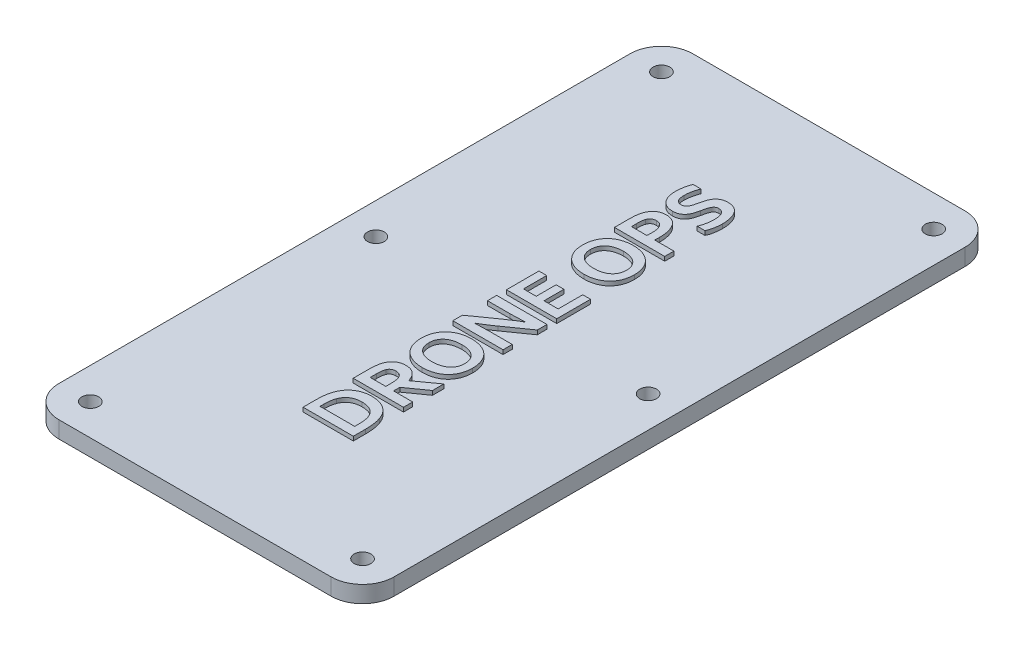
from build123d import *

# Parameters (mm, degrees)
CROQUIS1_W              = 80
CROQUIS1_H              = 151.368163876
CROQUIS1_R              = 2
SALIENTE_EXTRUIR1_DEPTH = 4
REDONDEO1_R             = 7.5
SALIENTE_EXTRUIR5_DEPTH = 1


with BuildPart() as part:
    # Croquis1 → Saliente-Extruir1 (new body)
    with BuildSketch(Plane(origin=(0, 0, 0), x_dir=(1, 0, 0), z_dir=(0, 1, 0))):
        with Locations((0, -7.276430304)):
            Rectangle(CROQUIS1_W, CROQUIS1_H)
        with Locations((32.5, 60.907651634)):
            Circle(CROQUIS1_R, mode=Mode.SUBTRACT)
        with Locations((-32.5, 60.907651634)):
            Circle(CROQUIS1_R, mode=Mode.SUBTRACT)
        with Locations((-32.5, -75.460512242)):
            Circle(CROQUIS1_R, mode=Mode.SUBTRACT)
        with Locations((32.5, -75.460512242)):
            Circle(CROQUIS1_R, mode=Mode.SUBTRACT)
        with Locations((-32.5, -7.276430304)):
            Circle(CROQUIS1_R, mode=Mode.SUBTRACT)
        with Locations((32.5, -7.276430304)):
            Circle(CROQUIS1_R, mode=Mode.SUBTRACT)
    extrude(amount=SALIENTE_EXTRUIR1_DEPTH)

    # Redondeo1
    redondeo1_edges = [part.edges().sort_by_distance(p)[0] for p in [
        (40, 2, 82.960512242),
        (-40, 2, 82.960512242),
        (-40, 2, -68.407651634),
        (40, 2, -68.407651634),
    ]]
    fillet(redondeo1_edges, radius=REDONDEO1_R)

    # Croquis3 → Saliente-Extruir5 (add)
    with BuildSketch(Plane(origin=(0, 4, 0), x_dir=(1, 0, 0), z_dir=(0, 1, 0))):
        with BuildLine():
            Line((7.049424333, -52.217275374), (-4.950575667, -52.217275374))
            Line((-4.950575667, -52.217275374), (-4.950575667, -48.995444388))
            add(Edge.make_bspline(
                [(-4.950575667, -48.995444388), (-4.948523154, -48.851949224), (-4.944378847, -48.562212774), (-4.92730262, -48.126087874), (-4.891577532, -47.693030468), (-4.848814952, -47.268061007), (-4.786358549, -46.857168032), (-4.716858455, -46.461269082), (-4.635295464, -46.086447791), (-4.563009273, -45.848910576), (-4.528040456, -45.734000726)],
                knots=[0, 0, 0, 0, 0.000430531, 0.000869301, 0.001309023, 0.001733937, 0.002150362, 0.002555454, 0.002939858, 0.00330007, 0.00330007, 0.00330007, 0.00330007], degree=3))
            add(Edge.make_bspline(
                [(-4.528040456, -45.734000726), (-4.474936266, -45.575552411), (-4.370571569, -45.264156821), (-4.176252716, -44.81949364), (-3.956494486, -44.402811884), (-3.711042013, -44.013622551), (-3.439225332, -43.653710927), (-3.141517627, -43.325944824), (-2.824552879, -43.024047985), (-2.479072213, -42.758648153), (-2.114049229, -42.518500696), (-1.725671208, -42.31424883), (-1.317946247, -42.138020243), (-0.89047826, -41.993357102), (-0.442788873, -41.879653782), (0.023331231, -41.798682343), (0.507738343, -41.746390407), (0.837139041, -41.741093735), (1.004529966, -41.738402135)],
                knots=[0, 0, 0, 0, 0.000501135, 0.000984871, 0.001453857, 0.001913227, 0.002363761, 0.002805027, 0.003240318, 0.003675064, 0.004110155, 0.004549623, 0.004989663, 0.005441464, 0.005901986, 0.00637393, 0.006859802, 0.007361813, 0.007361813, 0.007361813, 0.007361813], degree=3))
            add(Edge.make_bspline(
                [(1.004529966, -41.738402135), (1.163964766, -41.740610801), (1.478133149, -41.744963008), (1.941071201, -41.789184471), (2.388379819, -41.856893054), (2.819665016, -41.952527408), (3.235822859, -42.072044112), (3.631499436, -42.226351035), (4.009669927, -42.406760382), (4.369283718, -42.615769915), (4.710769506, -42.852572732), (5.028952578, -43.122279989), (5.328389333, -43.418130797), (5.605874188, -43.744642687), (5.86438984, -44.099861882), (6.095282593, -44.488521501), (6.303300473, -44.907802226), (6.417902524, -45.20309195), (6.476360952, -45.353719036)],
                knots=[0, 0, 0, 0, 0.000478175, 0.000942251, 0.001393804, 0.001834636, 0.002266678, 0.002691387, 0.003107167, 0.003522519, 0.003937905, 0.004352113, 0.004772273, 0.005199356, 0.005636214, 0.006088663, 0.006553991, 0.007038506, 0.007038506, 0.007038506, 0.007038506], degree=3))
            add(Edge.make_bspline(
                [(6.476360952, -45.353719036), (6.522989524, -45.48609498), (6.618730213, -45.757897513), (6.731996716, -46.185622881), (6.830484008, -46.638459376), (6.908312721, -47.118209271), (6.972500345, -47.625460889), (7.015498562, -48.163892985), (7.046669017, -48.732754074), (7.048491179, -49.123038972), (7.049424333, -49.322909177)],
                knots=[0, 0, 0, 0, 0.000420898, 0.000864214, 0.001326249, 0.001810763, 0.002321751, 0.002859719, 0.003430881, 0.004030405, 0.004030405, 0.004030405, 0.004030405], degree=3))
            Line((7.049424333, -49.322909177), (7.049424333, -52.217275374))
        make_face()
        with BuildLine():
            add(Edge.make_bspline(
                [(5.190269403, -49.106359881), (5.188764848, -48.948763947), (5.185837977, -48.642186404), (5.162748377, -48.195356713), (5.120339661, -47.775100407), (5.062758785, -47.3810956), (4.98999848, -47.013986169), (4.89910393, -46.673908578), (4.796609643, -46.358002573), (4.707868798, -46.162002275), (4.664741234, -46.066747205)],
                knots=[0, 0, 0, 0, 0.000472778, 0.000919713, 0.001341728, 0.00173948, 0.002113931, 0.002463681, 0.00279522, 0.003108692, 0.003108692, 0.003108692, 0.003108692], degree=3))
            add(Edge.make_bspline(
                [(4.664741234, -46.066747205), (4.624786689, -45.98760084), (4.545738823, -45.831014118), (4.403985814, -45.613028146), (4.252366127, -45.406734975), (4.087688843, -45.21557053), (3.90838738, -45.038969819), (3.71601359, -44.877950214), (3.508482324, -44.732767363), (3.289502122, -44.599805892), (3.054859143, -44.483916807), (2.807103884, -44.379289095), (2.540978352, -44.296980777), (2.261363664, -44.22366166), (1.964187815, -44.173239263), (1.652445644, -44.132809661), (1.324441651, -44.108966394), (1.100518365, -44.106076627), (0.986044051, -44.104599318)],
                knots=[0, 0, 0, 0, 0.000265796, 0.000525862, 0.00077886, 0.001033506, 0.001281872, 0.0015331, 0.001785145, 0.002041034, 0.002300859, 0.002569616, 0.002846892, 0.00313576, 0.003436214, 0.003750341, 0.004078667, 0.004422068, 0.004422068, 0.004422068, 0.004422068], degree=3))
            add(Edge.make_bspline(
                [(0.986044051, -44.104599318), (0.867162639, -44.106846616), (0.635198208, -44.111231602), (0.295141901, -44.139048642), (-0.026570389, -44.192879607), (-0.331274474, -44.263300309), (-0.618758465, -44.354218056), (-0.890478689, -44.461233906), (-1.145643673, -44.588856556), (-1.383618699, -44.734564211), (-1.606026287, -44.896239777), (-1.813873041, -45.072660057), (-2.000965376, -45.270724899), (-2.176152355, -45.481508175), (-2.334291533, -45.709084022), (-2.47645287, -45.950831838), (-2.60815122, -46.204497026), (-2.680011729, -46.38299776), (-2.716420738, -46.473437346)],
                knots=[0, 0, 0, 0, 0.000356671, 0.000695945, 0.001022428, 0.001334384, 0.001633394, 0.001926159, 0.002209604, 0.002488148, 0.0027623, 0.003033845, 0.00330467, 0.003578555, 0.003855479, 0.004134923, 0.004419559, 0.004711882, 0.004711882, 0.004711882, 0.004711882], degree=3))
            add(Edge.make_bspline(
                [(-2.716420738, -46.473437346), (-2.777152631, -46.654476562), (-2.903247191, -47.030359139), (-2.991598855, -47.529225794), (-3.045023243, -47.955889289), (-3.068680879, -48.301560594), (-3.089599031, -48.665968616), (-3.090803808, -48.915302922), (-3.091420738, -49.0429796)],
                knots=[0, 0, 0, 0, 0.000572186, 0.001188002, 0.001515232, 0.00186219, 0.002227095, 0.002610054, 0.002610054, 0.002610054, 0.002610054], degree=3))
            Line((-3.091420738, -49.0429796), (-3.091420738, -50.020092276))
            Line((-3.091420738, -50.020092276), (5.190269403, -50.020092276))
            Line((5.190269403, -50.020092276), (5.190269403, -49.106359881))
        make_face(mode=Mode.SUBTRACT)
        with BuildLine():
            add(Edge.make_bspline(
                [(-1.30620947, -31.284881008), (-1.202270164, -31.286910904), (-0.998293549, -31.29089449), (-0.697724688, -31.322270045), (-0.409787893, -31.379594677), (-0.131916212, -31.450610322), (0.131284482, -31.550931645), (0.384108127, -31.669100989), (0.623075788, -31.812809335), (0.852970533, -31.97366962), (1.066166658, -32.160238938), (1.269701454, -32.366193073), (1.45246747, -32.600727817), (1.626896867, -32.854760496), (1.780145643, -33.135994731), (1.924889828, -33.438182233), (2.050175123, -33.765730339), (2.121928774, -33.993992818), (2.158579262, -34.110585233)],
                knots=[0, 0, 0, 0, 0.000311799, 0.000611892, 0.000905038, 0.001192016, 0.001471123, 0.001748726, 0.002028169, 0.002306612, 0.002589331, 0.002876928, 0.00317388, 0.003480047, 0.003800417, 0.004133541, 0.004484684, 0.004851305, 0.004851305, 0.004851305, 0.004851305], degree=3))
            Line((2.158579262, -34.110585233), (2.192910248, -34.110585233))
            Line((2.192910248, -34.110585233), (7.049424333, -30.60882467))
            Line((7.049424333, -30.60882467), (7.049424333, -33.313050022))
            Line((7.049424333, -33.313050022), (2.486044051, -36.550726078))
            Line((2.486044051, -36.550726078), (2.486044051, -38.045444388))
            Line((2.486044051, -38.045444388), (7.049424333, -38.045444388))
            Line((7.049424333, -38.045444388), (7.049424333, -40.242627487))
            Line((7.049424333, -40.242627487), (-4.950575667, -40.242627487))
            Line((-4.950575667, -40.242627487), (-4.950575667, -36.561289459))
            add(Edge.make_bspline(
                [(-4.950575667, -36.561289459), (-4.950088257, -36.41160795), (-4.949127249, -36.116486736), (-4.925845242, -35.682436218), (-4.895679475, -35.263927428), (-4.850571483, -34.864044611), (-4.795092809, -34.485357291), (-4.719432395, -34.134410245), (-4.6379323, -33.810534951), (-4.567308899, -33.608392354), (-4.533322146, -33.511113402)],
                knots=[0, 0, 0, 0, 0.000448975, 0.000885226, 0.001303681, 0.001707592, 0.002092287, 0.002451218, 0.0027843, 0.00309329, 0.00309329, 0.00309329, 0.00309329], degree=3))
            add(Edge.make_bspline(
                [(-4.533322146, -33.511113402), (-4.498218957, -33.424422699), (-4.429273236, -33.254154609), (-4.310036886, -33.00885297), (-4.175197982, -32.780324941), (-4.029943156, -32.56574785), (-3.873883566, -32.366251361), (-3.704348366, -32.18333525), (-3.520828226, -32.016301656), (-3.325633995, -31.863893891), (-3.119709944, -31.723475682), (-2.89616069, -31.609792284), (-2.663301592, -31.507513654), (-2.416507032, -31.426156142), (-2.15690776, -31.362411372), (-1.884741214, -31.319380578), (-1.600088862, -31.287550101), (-1.40577702, -31.285785308), (-1.30620947, -31.284881008)],
                knots=[0, 0, 0, 0, 0.000280539, 0.000551004, 0.000817323, 0.001075884, 0.001327887, 0.001576421, 0.001823167, 0.002071463, 0.002319027, 0.002569448, 0.002822584, 0.003081468, 0.003347918, 0.003623605, 0.003907665, 0.004206186, 0.004206186, 0.004206186, 0.004206186], degree=3))
        make_face()
        with BuildLine():
            add(Edge.make_bspline(
                [(0.626889121, -36.9679796), (0.625321319, -36.847388761), (0.622322461, -36.616725194), (0.614956658, -36.284414485), (0.588480869, -35.981801038), (0.562248024, -35.704673392), (0.520576232, -35.453225338), (0.477364069, -35.221694675), (0.423158138, -35.011442966), (0.376881141, -34.880553617), (0.354882079, -34.818331712)],
                knots=[0, 0, 0, 0, 0.000361834, 0.000692109, 0.000996735, 0.001272915, 0.001526903, 0.001761002, 0.001979427, 0.002177349, 0.002177349, 0.002177349, 0.002177349], degree=3))
            add(Edge.make_bspline(
                [(0.354882079, -34.818331712), (0.312087135, -34.715637471), (0.23025709, -34.519271416), (0.066714585, -34.261732452), (-0.121474746, -34.054245072), (-0.333942007, -33.898760418), (-0.566350691, -33.787596362), (-0.813426851, -33.708469334), (-1.077184465, -33.659626313), (-1.258461918, -33.653969241), (-1.351103836, -33.651078191)],
                knots=[0, 0, 0, 0, 0.000333301, 0.00063732, 0.000910185, 0.001169001, 0.001421751, 0.001679811, 0.001945541, 0.002223282, 0.002223282, 0.002223282, 0.002223282], degree=3))
            add(Edge.make_bspline(
                [(-1.351103836, -33.651078191), (-1.430468487, -33.65368767), (-1.584812945, -33.658762455), (-1.810363012, -33.696273902), (-2.021128387, -33.760013627), (-2.220281361, -33.845661208), (-2.399320431, -33.967248509), (-2.561764085, -34.120867486), (-2.701258899, -34.312375989), (-2.773974021, -34.457990892), (-2.81149116, -34.533120445)],
                knots=[0, 0, 0, 0, 0.000238043, 0.000462933, 0.000683503, 0.000897477, 0.001110618, 0.001329171, 0.001565272, 0.001816929, 0.001816929, 0.001816929, 0.001816929], degree=3))
            add(Edge.make_bspline(
                [(-2.81149116, -34.533120445), (-2.834303543, -34.588273449), (-2.881811987, -34.703133583), (-2.939841821, -34.889345541), (-2.985979535, -35.096281357), (-3.02646471, -35.324332343), (-3.054076271, -35.576691892), (-3.075100414, -35.855011863), (-3.08808611, -36.160642618), (-3.090279279, -36.373776886), (-3.091420738, -36.484704952)],
                knots=[0, 0, 0, 0, 0.000178994, 0.000372768, 0.000584168, 0.000814709, 0.001067265, 0.001345358, 0.00165198, 0.001984769, 0.001984769, 0.001984769, 0.001984769], degree=3))
            Line((-3.091420738, -36.484704952), (-3.091420738, -38.045444388))
            Line((-3.091420738, -38.045444388), (0.626889121, -38.045444388))
            Line((0.626889121, -38.045444388), (0.626889121, -36.9679796))
        make_face(mode=Mode.SUBTRACT)
        with BuildLine():
            add(Edge.make_bspline(
                [(1.049424333, -17.958120445), (1.271465002, -17.962345895), (1.708020953, -17.970653586), (2.347706217, -18.046070388), (2.959357652, -18.169655763), (3.539673036, -18.344173074), (4.087804933, -18.562183321), (4.598928225, -18.827589361), (5.070347894, -19.139495353), (5.501075201, -19.497918992), (5.886966265, -19.900925871), (6.232053229, -20.345557317), (6.526563104, -20.835755896), (6.776526134, -21.367052712), (6.97439799, -21.938745782), (7.116940499, -22.55007293), (7.202005574, -23.199560151), (7.212873849, -23.64536228), (7.218438417, -23.873613402)],
                knots=[0, 0, 0, 0, 0.000665917, 0.001309265, 0.001929212, 0.002535779, 0.003124741, 0.003696433, 0.004260413, 0.004817306, 0.005373892, 0.005931166, 0.006502279, 0.007085876, 0.007689706, 0.008313617, 0.008966119, 0.009650715, 0.009650715, 0.009650715, 0.009650715], degree=3))
            add(Edge.make_bspline(
                [(7.218438417, -23.873613402), (7.212875077, -24.101865313), (7.202009199, -24.547668982), (7.116927035, -25.197145232), (6.974445439, -25.808511483), (6.776357472, -26.380065819), (6.527484277, -26.911174242), (6.230337831, -27.39960334), (5.887998527, -27.8461972), (5.500935034, -28.249218054), (5.070360996, -28.607690277), (4.59901979, -28.919898424), (4.087121754, -29.184165061), (3.540823172, -29.407223001), (2.958746645, -29.576480612), (2.347808391, -29.701476033), (1.707993954, -29.77648876), (1.2714559, -29.784852436), (1.049424333, -29.78910636)],
                knots=[0, 0, 0, 0, 0.000684595, 0.001337098, 0.001961008, 0.002564839, 0.003148436, 0.003717291, 0.004276658, 0.004833244, 0.005390137, 0.005954116, 0.006525809, 0.007115759, 0.007721572, 0.008341519, 0.008984867, 0.009650784, 0.009650784, 0.009650784, 0.009650784], degree=3))
            add(Edge.make_bspline(
                [(1.049424333, -29.78910636), (0.827383981, -29.78491661), (0.391703346, -29.776695613), (-0.247981767, -29.700901405), (-0.859103207, -29.576904173), (-1.44196563, -29.407176094), (-1.988275107, -29.184176942), (-2.500171507, -28.919895776), (-2.971508901, -28.607689333), (-3.402099532, -28.249224337), (-3.789100495, -27.846172945), (-4.131675807, -27.399695231), (-4.428113451, -26.910498783), (-4.680609265, -26.380751937), (-4.878830931, -25.808799077), (-5.017214361, -25.196755422), (-5.103400284, -24.547720611), (-5.114107597, -24.101882796), (-5.119589752, -23.873613402)],
                knots=[0, 0, 0, 0, 0.000665917, 0.001306642, 0.001929176, 0.00253499, 0.003124939, 0.003696632, 0.004260612, 0.004817504, 0.00537409, 0.005933457, 0.006502313, 0.007087038, 0.007690868, 0.00831418, 0.008966683, 0.009651278, 0.009651278, 0.009651278, 0.009651278], degree=3))
            add(Edge.make_bspline(
                [(-5.119589752, -23.873613402), (-5.114106372, -23.645344796), (-5.103396666, -23.199508517), (-5.017227791, -22.550462757), (-4.878783631, -21.938458107), (-4.680777716, -21.366366676), (-4.427187787, -20.836433757), (-4.133390607, -20.345465741), (-3.788068348, -19.900950066), (-3.40223969, -19.497912713), (-2.971495798, -19.139496305), (-2.500079953, -18.827591974), (-1.988958242, -18.562171582), (-1.440815674, -18.344219397), (-0.859716018, -18.169226442), (-0.247879888, -18.046644081), (0.391676387, -17.970446863), (0.82737488, -17.962281726), (1.049424333, -17.958120445)],
                knots=[0, 0, 0, 0, 0.000684595, 0.001337098, 0.00196041, 0.00256424, 0.003148966, 0.003720078, 0.004277353, 0.004833939, 0.005390832, 0.005954811, 0.006526504, 0.007115466, 0.007722033, 0.008344567, 0.008985292, 0.009651209, 0.009651209, 0.009651209, 0.009651209], degree=3))
        make_face()
        with BuildLine():
            add(Edge.make_bspline(
                [(1.049424333, -20.324317628), (0.87500092, -20.326956793), (0.536824062, -20.332073678), (0.045831608, -20.382985759), (-0.41172137, -20.466547432), (-0.835855597, -20.582517414), (-1.225541833, -20.727818868), (-1.581613852, -20.899259422), (-1.903980819, -21.098342715), (-2.191696037, -21.323317521), (-2.448659521, -21.568895854), (-2.665398048, -21.841759928), (-2.852983749, -22.133508227), (-3.002617835, -22.449095073), (-3.11940724, -22.782958498), (-3.199656857, -23.132944479), (-3.252690578, -23.497873107), (-3.257818225, -23.746659619), (-3.260434822, -23.873613402)],
                knots=[0, 0, 0, 0, 0.000523127, 0.001014254, 0.00147887, 0.001917091, 0.002331577, 0.002724886, 0.003100833, 0.003465863, 0.003818838, 0.004164456, 0.00450878, 0.004857231, 0.005209683, 0.005567759, 0.005933017, 0.006313629, 0.006313629, 0.006313629, 0.006313629], degree=3))
            add(Edge.make_bspline(
                [(-3.260434822, -23.873613402), (-3.257818146, -24.0005671), (-3.252690343, -24.249353446), (-3.199657743, -24.61428328), (-3.119404005, -24.964264825), (-3.002629655, -25.29814445), (-2.852940384, -25.613671915), (-2.665558077, -25.905639072), (-2.447669859, -26.178160156), (-2.193519408, -26.426891312), (-1.90291108, -26.64841823), (-1.581787821, -26.84818127), (-1.225491579, -27.019346152), (-0.835870208, -27.164727355), (-0.411717104, -27.280674128), (0.04583037, -27.364242567), (0.536824402, -27.415152708), (0.875001036, -27.42026987), (1.049424333, -27.422909177)],
                knots=[0, 0, 0, 0, 0.000380612, 0.00074587, 0.001103946, 0.001456397, 0.001804849, 0.002149173, 0.002494791, 0.002849609, 0.00321302, 0.003588967, 0.003982276, 0.004396762, 0.004834984, 0.0052996, 0.005790726, 0.006313853, 0.006313853, 0.006313853, 0.006313853], degree=3))
            add(Edge.make_bspline(
                [(1.049424333, -27.422909177), (1.223849823, -27.420277818), (1.562030712, -27.415176067), (2.052994865, -27.364157702), (2.509810752, -27.281118642), (2.932811889, -27.164212459), (3.321730295, -27.019424902), (3.677934353, -26.848075953), (3.998729722, -26.649112684), (4.287420445, -26.42699933), (4.538425043, -26.176447272), (4.75944025, -25.906635579), (4.946491749, -25.613588588), (5.095752928, -25.297673683), (5.215562125, -24.964436838), (5.299167638, -24.61462576), (5.351356485, -24.249316488), (5.35660514, -24.000554613), (5.359283488, -23.873613402)],
                knots=[0, 0, 0, 0, 0.000523127, 0.001014254, 0.00147887, 0.001914545, 0.002329032, 0.00272234, 0.003098288, 0.003459611, 0.003812547, 0.004159825, 0.004504149, 0.004852601, 0.005205932, 0.00556462, 0.005929879, 0.00631049, 0.00631049, 0.00631049, 0.00631049], degree=3))
            add(Edge.make_bspline(
                [(5.359283488, -23.873613402), (5.35660522, -23.746672107), (5.35135672, -23.497910065), (5.299166746, -23.132601995), (5.215565387, -22.78278649), (5.095741013, -22.449565823), (4.946535338, -22.133591747), (4.759279055, -21.840763075), (4.539427422, -21.570607268), (4.285597138, -21.323189395), (3.999806378, -21.097651654), (3.677758859, -20.899364569), (3.321780999, -20.727740156), (2.932797245, -20.583032179), (2.509815045, -20.466102934), (2.052993616, -20.383070623), (1.562031055, -20.33205032), (1.22384994, -20.326948845), (1.049424333, -20.324317628)],
                knots=[0, 0, 0, 0, 0.000380612, 0.00074587, 0.001104559, 0.00145789, 0.001806341, 0.002150665, 0.002497944, 0.002849027, 0.003211978, 0.003587925, 0.003981234, 0.00439572, 0.004831396, 0.005296012, 0.005787138, 0.006310265, 0.006310265, 0.006310265, 0.006310265], degree=3))
        make_face(mode=Mode.SUBTRACT)
        with BuildLine():
            add(Edge.make_bspline(
                [(0.629529966, -10.222028895), (0.780964497, -10.117316852), (1.078202156, -9.911786696), (1.515565324, -9.608351209), (1.944694797, -9.327219892), (2.359224613, -9.057733701), (2.759037914, -8.800722087), (3.149297253, -8.563081533), (3.524946059, -8.339026874), (3.772815283, -8.197037397), (3.893614473, -8.127838755)],
                knots=[0, 0, 0, 0, 0.000552341, 0.001084142, 0.001596853, 0.002091284, 0.002567465, 0.003022649, 0.003461966, 0.003879604, 0.003879604, 0.003879604, 0.003879604], degree=3))
            Line((3.893614473, -8.127838755), (3.893614473, -8.075021853))
            add(Edge.make_bspline(
                [(3.893614473, -8.075021853), (3.705237021, -8.083010445), (3.341699485, -8.098427115), (2.816172845, -8.11964457), (2.330248413, -8.137862504), (1.884003732, -8.154825628), (1.477256451, -8.16463032), (1.111062316, -8.17274632), (0.78447436, -8.178345879), (0.580235809, -8.179917364), (0.484283488, -8.180655656)],
                knots=[0, 0, 0, 0, 0.00056564, 0.001091593, 0.00157786, 0.002024444, 0.002431271, 0.002798434, 0.003123301, 0.003411165, 0.003411165, 0.003411165, 0.003411165], degree=3))
            Line((0.484283488, -8.180655656), (-4.950575667, -8.180655656))
            Line((-4.950575667, -8.180655656), (-4.950575667, -5.983472557))
            Line((-4.950575667, -5.983472557), (7.049424333, -5.983472557))
            Line((7.049424333, -5.983472557), (7.049424333, -8.283648614))
            Line((7.049424333, -8.283648614), (1.524776445, -12.186817628))
            add(Edge.make_bspline(
                [(1.524776445, -12.186817628), (1.277547255, -12.361707875), (0.768790756, -12.721602876), (-0.035770077, -13.247846362), (-0.897157935, -13.784542801), (-1.495567469, -14.137058479), (-1.802688343, -14.3179796)],
                knots=[0, 0, 0, 0, 0.000908439, 0.001869417, 0.002883601, 0.003952908, 0.003952908, 0.003952908, 0.003952908], degree=3))
            Line((-1.802688343, -14.3179796), (-1.802688343, -14.373437346))
            add(Edge.make_bspline(
                [(-1.802688343, -14.373437346), (-1.624006364, -14.364305768), (-1.277261275, -14.346585291), (-0.772779926, -14.326217518), (-0.299191487, -14.307707785), (0.143539128, -14.290882472), (0.555569315, -14.281093658), (0.935848215, -14.272940261), (1.285325643, -14.267412066), (1.508049536, -14.265890414), (1.614565178, -14.265162698)],
                knots=[0, 0, 0, 0, 0.000536742, 0.001041585, 0.001514658, 0.001958603, 0.00237071, 0.002751074, 0.003099706, 0.003419259, 0.003419259, 0.003419259, 0.003419259], degree=3))
            Line((1.614565178, -14.265162698), (7.049424333, -14.265162698))
            Line((7.049424333, -14.265162698), (7.049424333, -16.462345797))
            Line((7.049424333, -16.462345797), (-4.950575667, -16.462345797))
            Line((-4.950575667, -16.462345797), (-4.950575667, -14.16216974))
            Line((-4.950575667, -14.16216974), (0.629529966, -10.222028895))
        make_face()
        Polygon((5.190269403, -1.445444388), (5.190269403, 4.419872513), (7.049424333, 4.419872513), (7.049424333, -3.642627487), (-4.950575667, -3.642627487), (-4.950575667, 4.097689414), (-3.091420738, 4.097689414), (-3.091420738, -1.445444388), (-0.049167217, -1.445444388), (-0.049167217, 3.313358429), (1.809987713, 3.313358429), (1.809987713, -1.445444388), align=None)
        with BuildLine():
            add(Edge.make_bspline(
                [(1.049424333, 20.644696457), (1.271465002, 20.640471007), (1.708020953, 20.632163315), (2.347706217, 20.556746514), (2.959357652, 20.433161138), (3.539673036, 20.258643828), (4.087804933, 20.04063358), (4.598928225, 19.77522754), (5.070347894, 19.463321548), (5.501075201, 19.104897909), (5.886966265, 18.70189103), (6.232053229, 18.257259584), (6.526563104, 17.767061006), (6.776526134, 17.23576419), (6.97439799, 16.664071119), (7.116940499, 16.052743971), (7.202005574, 15.403256751), (7.212873849, 14.957454621), (7.218438417, 14.729203499)],
                knots=[0, 0, 0, 0, 0.000665917, 0.001309265, 0.001929212, 0.002535779, 0.003124741, 0.003696433, 0.004260413, 0.004817306, 0.005373892, 0.005931166, 0.006502279, 0.007085876, 0.007689706, 0.008313617, 0.008966119, 0.009650715, 0.009650715, 0.009650715, 0.009650715], degree=3))
            add(Edge.make_bspline(
                [(7.218438417, 14.729203499), (7.212875077, 14.500951589), (7.202009199, 14.05514792), (7.116927035, 13.40567167), (6.974445439, 12.794305419), (6.776357472, 12.222751082), (6.527484277, 11.691642659), (6.230337831, 11.203213562), (5.887998527, 10.756619701), (5.500935034, 10.353598848), (5.070360996, 9.995126624), (4.59901979, 9.682918478), (4.087121754, 9.41865184), (3.540823172, 9.195593901), (2.958746645, 9.026336289), (2.347808391, 8.901340868), (1.707993954, 8.826328141), (1.2714559, 8.817964466), (1.049424333, 8.813710541)],
                knots=[0, 0, 0, 0, 0.000684595, 0.001337098, 0.001961008, 0.002564839, 0.003148436, 0.003717291, 0.004276658, 0.004833244, 0.005390137, 0.005954116, 0.006525809, 0.007115759, 0.007721572, 0.008341519, 0.008984867, 0.009650784, 0.009650784, 0.009650784, 0.009650784], degree=3))
            add(Edge.make_bspline(
                [(1.049424333, 8.813710541), (0.827383981, 8.817900292), (0.391703346, 8.826121289), (-0.247981767, 8.901915496), (-0.859103207, 9.025912728), (-1.44196563, 9.195640807), (-1.988275107, 9.41863996), (-2.500171507, 9.682921125), (-2.971508901, 9.995127569), (-3.402099532, 10.353592564), (-3.789100495, 10.756643957), (-4.131675807, 11.20312167), (-4.428113451, 11.692318118), (-4.680609265, 12.222064964), (-4.878830931, 12.794017824), (-5.017214361, 13.406061479), (-5.103400284, 14.05509629), (-5.114107597, 14.500934106), (-5.119589752, 14.729203499)],
                knots=[0, 0, 0, 0, 0.000665917, 0.001306642, 0.001929176, 0.00253499, 0.003124939, 0.003696632, 0.004260612, 0.004817504, 0.00537409, 0.005933457, 0.006502313, 0.007087038, 0.007690868, 0.00831418, 0.008966683, 0.009651278, 0.009651278, 0.009651278, 0.009651278], degree=3))
            add(Edge.make_bspline(
                [(-5.119589752, 14.729203499), (-5.114106372, 14.957472105), (-5.103396666, 15.403308384), (-5.017227791, 16.052354145), (-4.878783631, 16.664358794), (-4.680777716, 17.236450225), (-4.427187787, 17.766383145), (-4.133390607, 18.257351161), (-3.788068348, 18.701866836), (-3.40223969, 19.104904189), (-2.971495798, 19.463320597), (-2.500079953, 19.775224927), (-1.988958242, 20.040645319), (-1.440815674, 20.258597505), (-0.859716018, 20.43359046), (-0.247879888, 20.556172821), (0.391676387, 20.632370038), (0.82737488, 20.640535175), (1.049424333, 20.644696457)],
                knots=[0, 0, 0, 0, 0.000684595, 0.001337098, 0.00196041, 0.00256424, 0.003148966, 0.003720078, 0.004277353, 0.004833939, 0.005390832, 0.005954811, 0.006526504, 0.007115466, 0.007722033, 0.008344567, 0.008985292, 0.009651209, 0.009651209, 0.009651209, 0.009651209], degree=3))
        make_face()
        with BuildLine():
            add(Edge.make_bspline(
                [(1.049424333, 18.278499274), (0.87500092, 18.275860109), (0.536824062, 18.270743224), (0.045831608, 18.219831143), (-0.41172137, 18.13626947), (-0.835855597, 18.020299488), (-1.225541833, 17.874998033), (-1.581613852, 17.70355748), (-1.903980819, 17.504474186), (-2.191696037, 17.279499381), (-2.448659521, 17.033921048), (-2.665398048, 16.761056973), (-2.852983749, 16.469308674), (-3.002617835, 16.153721828), (-3.11940724, 15.819858403), (-3.199656857, 15.469872422), (-3.252690578, 15.104943794), (-3.257818225, 14.856157282), (-3.260434822, 14.729203499)],
                knots=[0, 0, 0, 0, 0.000523127, 0.001014254, 0.00147887, 0.001917091, 0.002331577, 0.002724886, 0.003100833, 0.003465863, 0.003818838, 0.004164456, 0.00450878, 0.004857231, 0.005209683, 0.005567759, 0.005933017, 0.006313629, 0.006313629, 0.006313629, 0.006313629], degree=3))
            add(Edge.make_bspline(
                [(-3.260434822, 14.729203499), (-3.257818146, 14.602249801), (-3.252690343, 14.353463456), (-3.199657743, 13.988533621), (-3.119404005, 13.638552076), (-3.002629655, 13.304672451), (-2.852940384, 12.989144986), (-2.665558077, 12.697177829), (-2.447669859, 12.424656745), (-2.193519408, 12.17592559), (-1.90291108, 11.954398671), (-1.581787821, 11.754635631), (-1.225491579, 11.58347075), (-0.835870208, 11.438089547), (-0.411717104, 11.322142773), (0.04583037, 11.238574334), (0.536824402, 11.187664193), (0.875001036, 11.182547032), (1.049424333, 11.179907724)],
                knots=[0, 0, 0, 0, 0.000380612, 0.00074587, 0.001103946, 0.001456397, 0.001804849, 0.002149173, 0.002494791, 0.002849609, 0.00321302, 0.003588967, 0.003982276, 0.004396762, 0.004834984, 0.0052996, 0.005790726, 0.006313853, 0.006313853, 0.006313853, 0.006313853], degree=3))
            add(Edge.make_bspline(
                [(1.049424333, 11.179907724), (1.223849823, 11.182539084), (1.562030712, 11.187640835), (2.052994865, 11.2386592), (2.509810752, 11.321698259), (2.932811889, 11.438604442), (3.321730295, 11.583391999), (3.677934353, 11.754740949), (3.998729722, 11.953704217), (4.287420445, 12.175817572), (4.538425043, 12.42636963), (4.75944025, 12.696181322), (4.946491749, 12.989228313), (5.095752928, 13.305143218), (5.215562125, 13.638380064), (5.299167638, 13.988191141), (5.351356485, 14.353500413), (5.35660514, 14.602262288), (5.359283488, 14.729203499)],
                knots=[0, 0, 0, 0, 0.000523127, 0.001014254, 0.00147887, 0.001914545, 0.002329032, 0.00272234, 0.003098288, 0.003459611, 0.003812547, 0.004159825, 0.004504149, 0.004852601, 0.005205932, 0.00556462, 0.005929879, 0.00631049, 0.00631049, 0.00631049, 0.00631049], degree=3))
            add(Edge.make_bspline(
                [(5.359283488, 14.729203499), (5.35660522, 14.856144795), (5.35135672, 15.104906836), (5.299166746, 15.470214906), (5.215565387, 15.820030412), (5.095741013, 16.153251078), (4.946535338, 16.469225155), (4.759279055, 16.762053827), (4.539427422, 17.032209634), (4.285597138, 17.279627506), (3.999806378, 17.505165247), (3.677758859, 17.703452332), (3.321780999, 17.875076745), (2.932797245, 18.019784723), (2.509815045, 18.136713967), (2.052993616, 18.219746278), (1.562031055, 18.270766582), (1.22384994, 18.275868057), (1.049424333, 18.278499274)],
                knots=[0, 0, 0, 0, 0.000380612, 0.00074587, 0.001104559, 0.00145789, 0.001806341, 0.002150665, 0.002497944, 0.002849027, 0.003211978, 0.003587925, 0.003981234, 0.00439572, 0.004831396, 0.005296012, 0.005787138, 0.006310265, 0.006310265, 0.006310265, 0.006310265], degree=3))
        make_face(mode=Mode.SUBTRACT)
        with BuildLine():
            add(Edge.make_bspline(
                [(2.486044051, 25.473217584), (2.485549332, 25.37461919), (2.484559738, 25.177390969), (2.476281047, 24.886867451), (2.464687341, 24.606693115), (2.448847266, 24.425638701), (2.441149685, 24.337654203)],
                knots=[0, 0, 0, 0, 0.000295786, 0.000591667, 0.000871908, 0.001136836, 0.001136836, 0.001136836, 0.001136836], degree=3))
            Line((2.441149685, 24.337654203), (7.049424333, 24.337654203))
            Line((7.049424333, 24.337654203), (7.049424333, 22.140471105))
            Line((7.049424333, 22.140471105), (-4.950575667, 22.140471105))
            Line((-4.950575667, 22.140471105), (-4.950575667, 25.636949978))
            add(Edge.make_bspline(
                [(-4.950575667, 25.636949978), (-4.9493777, 25.778684605), (-4.947055643, 26.053413062), (-4.93449816, 26.451482359), (-4.911423386, 26.822366977), (-4.876009647, 27.166508795), (-4.835896679, 27.489548042), (-4.777966816, 27.790776379), (-4.720452949, 28.076749704), (-4.667500358, 28.257860502), (-4.641596794, 28.34645702)],
                knots=[0, 0, 0, 0, 0.000425209, 0.000824195, 0.001194677, 0.001539699, 0.001862022, 0.002170742, 0.002459766, 0.002736552, 0.002736552, 0.002736552, 0.002736552], degree=3))
            add(Edge.make_bspline(
                [(-4.641596794, 28.34645702), (-4.608429012, 28.447223759), (-4.543158096, 28.645522743), (-4.427370802, 28.929875983), (-4.297265581, 29.19663213), (-4.152199574, 29.444515185), (-3.992842581, 29.676091677), (-3.819783861, 29.889853141), (-3.629955838, 30.083418904), (-3.42921888, 30.26172996), (-3.213504728, 30.420661834), (-2.981165579, 30.554985224), (-2.737343799, 30.672636911), (-2.478378643, 30.767926014), (-2.203675086, 30.838128519), (-1.916147824, 30.891169659), (-1.614157912, 30.923385502), (-1.408400673, 30.927239772), (-1.303568625, 30.929203499)],
                knots=[0, 0, 0, 0, 0.000318186, 0.000626159, 0.000920243, 0.001207853, 0.001486946, 0.001762874, 0.002031799, 0.00229936, 0.002567689, 0.002834008, 0.003103323, 0.003379035, 0.003660232, 0.00395289, 0.00425561, 0.004570048, 0.004570048, 0.004570048, 0.004570048], degree=3))
            add(Edge.make_bspline(
                [(-1.303568625, 30.929203499), (-1.160748712, 30.924260788), (-0.880596154, 30.914565269), (-0.469876794, 30.849346999), (-0.08337392, 30.731063094), (0.282332184, 30.572913839), (0.620625896, 30.367322239), (0.936431183, 30.123859393), (1.219559664, 29.831231958), (1.47857367, 29.500040611), (1.711499631, 29.129759715), (1.911610137, 28.718769804), (2.086435985, 28.271229606), (2.229912169, 27.784123464), (2.347207284, 27.260402436), (2.426597789, 26.697884022), (2.478410271, 26.098314624), (2.483451856, 25.685481162), (2.486044051, 25.473217584)],
                knots=[0, 0, 0, 0, 0.000428477, 0.000840491, 0.001243183, 0.001638155, 0.002032632, 0.002427772, 0.002831138, 0.003250601, 0.003687291, 0.00414081, 0.00461994, 0.005127099, 0.005662741, 0.006228554, 0.006830122, 0.007466763, 0.007466763, 0.007466763, 0.007466763], degree=3))
        make_face()
        with BuildLine():
            add(Edge.make_bspline(
                [(0.571431375, 24.337654203), (0.581241432, 24.40886203), (0.603093032, 24.567475273), (0.614218077, 24.827034399), (0.626313071, 25.116586542), (0.626695472, 25.318268389), (0.626889121, 25.420400682)],
                knots=[0, 0, 0, 0, 0.000215532, 0.000480092, 0.000778694, 0.001085044, 0.001085044, 0.001085044, 0.001085044], degree=3))
            add(Edge.make_bspline(
                [(0.626889121, 25.420400682), (0.626040469, 25.562195733), (0.624409673, 25.834673385), (0.593546564, 26.224982921), (0.551244814, 26.579946616), (0.48718564, 26.899199117), (0.408714377, 27.186435299), (0.313635803, 27.443391884), (0.205793208, 27.671934627), (0.084149584, 27.87325543), (-0.054090917, 28.044819417), (-0.202785511, 28.193653267), (-0.367951346, 28.313424402), (-0.547101869, 28.405444922), (-0.735007159, 28.476939045), (-0.932505964, 28.527559676), (-1.13898022, 28.556400826), (-1.279713184, 28.560783224), (-1.351103836, 28.563006316)],
                knots=[0, 0, 0, 0, 0.00042525, 0.000817173, 0.001173883, 0.00149706, 0.00179307, 0.002066305, 0.002317907, 0.002550257, 0.002770082, 0.002977367, 0.003179681, 0.003379305, 0.003579905, 0.003781666, 0.003989691, 0.00420386, 0.00420386, 0.00420386, 0.00420386], degree=3))
            add(Edge.make_bspline(
                [(-1.351103836, 28.563006316), (-1.437581347, 28.560002472), (-1.604730288, 28.554196461), (-1.847516439, 28.508031072), (-2.071809163, 28.4320292), (-2.280107685, 28.325110545), (-2.469999528, 28.18087015), (-2.631217236, 27.986492202), (-2.776155367, 27.752714313), (-2.84607019, 27.574086643), (-2.882793977, 27.480259837)],
                knots=[0, 0, 0, 0, 0.000259287, 0.000501166, 0.000738343, 0.000967489, 0.001200961, 0.001448159, 0.001720819, 0.0020225, 0.0020225, 0.0020225, 0.0020225], degree=3))
            add(Edge.make_bspline(
                [(-2.882793977, 27.480259837), (-2.900369154, 27.425033255), (-2.937122723, 27.309542295), (-2.977288909, 27.123610054), (-3.015070896, 26.920401198), (-3.043679411, 26.697337404), (-3.064083798, 26.452335021), (-3.079534607, 26.182875304), (-3.090825476, 25.887044067), (-3.091216782, 25.680975899), (-3.091420738, 25.573569696)],
                knots=[0, 0, 0, 0, 0.000173775, 0.000363401, 0.00057008, 0.000793805, 0.00103768, 0.001307512, 0.001603475, 0.001925669, 0.001925669, 0.001925669, 0.001925669], degree=3))
            Line((-3.091420738, 25.573569696), (-3.091420738, 24.337654203))
            Line((-3.091420738, 24.337654203), (0.571431375, 24.337654203))
        make_face(mode=Mode.SUBTRACT)
        with BuildLine():
            add(Edge.make_bspline(
                [(3.581994755, 38.509485189), (3.50953781, 38.507552706), (3.371167741, 38.50386227), (3.174583562, 38.459277825), (2.998250659, 38.392525737), (2.844670485, 38.293507346), (2.708777158, 38.173794147), (2.590506244, 38.030884298), (2.480387829, 37.87204848), (2.35406888, 37.626225125), (2.218430239, 37.284720391), (2.097461212, 36.836982871), (1.989602288, 36.357978088), (1.919677596, 36.028930232), (1.883931375, 35.860717584)],
                knots=[0, 0, 0, 0, 0.000216951, 0.000414309, 0.000601642, 0.000779679, 0.000959295, 0.001142905, 0.001334817, 0.001538007, 0.001970534, 0.002434489, 0.002927755, 0.003443646, 0.003443646, 0.003443646, 0.003443646], degree=3))
            add(Edge.make_bspline(
                [(1.883931375, 35.860717584), (1.831834522, 35.637364283), (1.729125771, 35.197024084), (1.566261783, 34.66147487), (1.417106537, 34.253162046), (1.280813844, 33.969138381), (1.125930477, 33.702892834), (0.950971909, 33.455521173), (0.755021683, 33.228545391), (0.532240298, 33.026156269), (0.280650152, 32.853002638), (0.008551381, 32.696399385), (-0.297604033, 32.573602189), (-0.637771689, 32.488360947), (-1.013160491, 32.434890349), (-1.275207354, 32.428375241), (-1.411843273, 32.424978147)],
                knots=[0, 0, 0, 0, 0.000687903, 0.001356199, 0.00167796, 0.001990986, 0.002299886, 0.002601047, 0.002898666, 0.003197817, 0.003501135, 0.003813303, 0.004137944, 0.004487026, 0.004863112, 0.00527286, 0.00527286, 0.00527286, 0.00527286], degree=3))
            add(Edge.make_bspline(
                [(-1.411843273, 32.424978147), (-1.564382232, 32.42857863), (-1.860427294, 32.435566388), (-2.288693894, 32.502576882), (-2.685866086, 32.613602599), (-3.051685079, 32.767383201), (-3.387180559, 32.95896602), (-3.691451426, 33.184945698), (-3.968688634, 33.439892976), (-4.215303643, 33.726006892), (-4.427085845, 34.041208943), (-4.613636946, 34.376852797), (-4.773080163, 34.733212938), (-4.897883576, 35.113587677), (-5.000939407, 35.513600567), (-5.065184775, 35.937535933), (-5.114228438, 36.381587917), (-5.117777905, 36.685392345), (-5.119589752, 36.840471105)],
                knots=[0, 0, 0, 0, 0.000457354, 0.000887626, 0.001296445, 0.001691761, 0.002075003, 0.002452653, 0.002826423, 0.003202806, 0.003582959, 0.003963608, 0.004353747, 0.004752095, 0.005163296, 0.005591373, 0.006037301, 0.006502277, 0.006502277, 0.006502277, 0.006502277], degree=3))
            add(Edge.make_bspline(
                [(-5.119589752, 36.840471105), (-5.1181117, 36.999894269), (-5.115151545, 37.319177748), (-5.073765024, 37.797248044), (-5.021444272, 38.277246803), (-4.938587238, 38.751777079), (-4.839560355, 39.211570093), (-4.727604792, 39.645013014), (-4.598788836, 40.044213566), (-4.499386301, 40.295168686), (-4.451455949, 40.41617533)],
                knots=[0, 0, 0, 0, 0.00047811, 0.00095753, 0.00143873, 0.001926286, 0.002401785, 0.002849523, 0.003268761, 0.00365915, 0.00365915, 0.00365915, 0.00365915], degree=3))
            Line((-4.451455949, 40.41617533), (-2.584378484, 40.41617533))
            add(Edge.make_bspline(
                [(-2.584378484, 40.41617533), (-2.641415922, 40.263548676), (-2.753338236, 39.964055412), (-2.891630299, 39.512663987), (-3.012393436, 39.073082484), (-3.104779868, 38.641758671), (-3.171930014, 38.222707915), (-3.224078813, 37.815995566), (-3.253167936, 37.421886785), (-3.258047588, 37.162695675), (-3.260434822, 37.03589364)],
                knots=[0, 0, 0, 0, 0.000488699, 0.000958955, 0.001415707, 0.001855976, 0.002281447, 0.0026886, 0.003085791, 0.003466219, 0.003466219, 0.003466219, 0.003466219], degree=3))
            add(Edge.make_bspline(
                [(-3.260434822, 37.03589364), (-3.259682288, 36.948711422), (-3.258220973, 36.779415846), (-3.239414305, 36.532491465), (-3.20813899, 36.301504986), (-3.165436812, 36.085535692), (-3.11388748, 35.884582678), (-3.04805967, 35.698722803), (-2.968305067, 35.529514618), (-2.878904792, 35.374511926), (-2.775868871, 35.237303448), (-2.661663961, 35.116373443), (-2.533595673, 35.014965368), (-2.392774819, 34.933232494), (-2.240301443, 34.868481354), (-2.075593695, 34.825490448), (-1.899846781, 34.793755728), (-1.778196443, 34.792052551), (-1.715540456, 34.79117533)],
                knots=[0, 0, 0, 0, 0.000261497, 0.00050779, 0.000742335, 0.000960377, 0.001167915, 0.00136421, 0.001550871, 0.001728417, 0.001900072, 0.002064442, 0.002226117, 0.002388266, 0.002551593, 0.002721369, 0.002898069, 0.003085736, 0.003085736, 0.003085736, 0.003085736], degree=3))
            add(Edge.make_bspline(
                [(-1.715540456, 34.79117533), (-1.643150791, 34.792517506), (-1.503487411, 34.795107004), (-1.304976991, 34.834014679), (-1.125030596, 34.890292979), (-0.966379812, 34.974571392), (-0.825978003, 35.079072148), (-0.698642182, 35.19962037), (-0.580340573, 35.333724705), (-0.446462178, 35.545783834), (-0.297252172, 35.840682761), (-0.171421437, 36.239735342), (-0.06363751, 36.670728985), (0.001781256, 36.969683572), (0.035339826, 37.123041527)],
                knots=[0, 0, 0, 0, 0.000216807, 0.000418291, 0.000604522, 0.00078053, 0.000954305, 0.00112806, 0.00130594, 0.001489056, 0.001878793, 0.002293842, 0.002740918, 0.003211826, 0.003211826, 0.003211826, 0.003211826], degree=3))
            add(Edge.make_bspline(
                [(0.035339826, 37.123041527), (0.091728429, 37.365540281), (0.202400255, 37.841483618), (0.363673834, 38.423944427), (0.512703414, 38.86875388), (0.650625543, 39.177503351), (0.80458572, 39.470101735), (0.980614663, 39.74184063), (1.181767628, 39.992878916), (1.412731682, 40.216444914), (1.674325041, 40.409035331), (1.96203728, 40.578329626), (2.286524789, 40.716338645), (2.653636896, 40.807389325), (3.060662015, 40.86729292), (3.345839752, 40.872803211), (3.494846868, 40.875682372)],
                knots=[0, 0, 0, 0, 0.000746855, 0.001465825, 0.00181242, 0.002152956, 0.002479023, 0.002803514, 0.003122739, 0.003442107, 0.00376482, 0.00409501, 0.004441776, 0.004818409, 0.005226614, 0.0056733, 0.0056733, 0.0056733, 0.0056733], degree=3))
            add(Edge.make_bspline(
                [(3.494846868, 40.875682372), (3.649125889, 40.871027768), (3.949598855, 40.861962485), (4.384973846, 40.794356344), (4.787479717, 40.674285224), (5.157537771, 40.509747316), (5.496630537, 40.301699883), (5.803277303, 40.051796382), (6.082025393, 39.764257117), (6.322656742, 39.434419416), (6.537545311, 39.07241423), (6.725601791, 38.67992352), (6.877619551, 38.252369484), (7.003336086, 37.797766504), (7.100990901, 37.31589811), (7.167537248, 36.812010232), (7.212095516, 36.286694186), (7.216295082, 35.929475316), (7.218438417, 35.747161245)],
                knots=[0, 0, 0, 0, 0.000462759, 0.000901266, 0.001317365, 0.001719303, 0.002112895, 0.002507187, 0.002903137, 0.003310889, 0.003728919, 0.004164795, 0.004614235, 0.005088361, 0.005578826, 0.006087879, 0.006612471, 0.007159286, 0.007159286, 0.007159286, 0.007159286], degree=3))
            add(Edge.make_bspline(
                [(7.218438417, 35.747161245), (7.21691218, 35.58598388), (7.213863925, 35.26407474), (7.1735896, 34.784025246), (7.11792013, 34.306698406), (7.032249943, 33.840180939), (6.933298019, 33.394014954), (6.811461949, 32.981740786), (6.671574565, 32.607857653), (6.555818895, 32.379183826), (6.500128558, 32.269168288)],
                knots=[0, 0, 0, 0, 0.00048339, 0.000965444, 0.001444333, 0.001924539, 0.002387719, 0.002814696, 0.003213428, 0.003583118, 0.003583118, 0.003583118, 0.003583118], degree=3))
            Line((6.500128558, 32.269168288), (4.68322715, 32.269168288))
            add(Edge.make_bspline(
                [(4.68322715, 32.269168288), (4.738935698, 32.414881304), (4.848925838, 32.702574946), (4.991849699, 33.134661741), (5.108835732, 33.562246503), (5.20117581, 33.986414071), (5.273517071, 34.411957054), (5.323231154, 34.842137427), (5.352577027, 35.278439535), (5.357040474, 35.571061034), (5.359283488, 35.71811195)],
                knots=[0, 0, 0, 0, 0.000467959, 0.000923931, 0.001364699, 0.001797226, 0.002225735, 0.002659107, 0.003095814, 0.003536962, 0.003536962, 0.003536962, 0.003536962], degree=3))
            add(Edge.make_bspline(
                [(5.359283488, 35.71811195), (5.355318643, 35.889093651), (5.347422911, 36.229592675), (5.292123006, 36.649582376), (5.231397493, 36.975579839), (5.167007986, 37.206691746), (5.089236572, 37.425551767), (4.99272221, 37.630027048), (4.884361126, 37.821128952), (4.752617292, 37.990480076), (4.607390819, 38.144319152), (4.43995357, 38.272408823), (4.256779851, 38.382172984), (4.049323131, 38.454772196), (3.822581397, 38.500799957), (3.664102172, 38.506521093), (3.581994755, 38.509485189)],
                knots=[0, 0, 0, 0, 0.000512759, 0.001021127, 0.001268691, 0.001507027, 0.001740095, 0.001964567, 0.002184694, 0.002397557, 0.002606734, 0.002817506, 0.003028129, 0.003244501, 0.003473418, 0.003719528, 0.003719528, 0.003719528, 0.003719528], degree=3))
        make_face()
    extrude(amount=SALIENTE_EXTRUIR5_DEPTH)


solid = part.part
